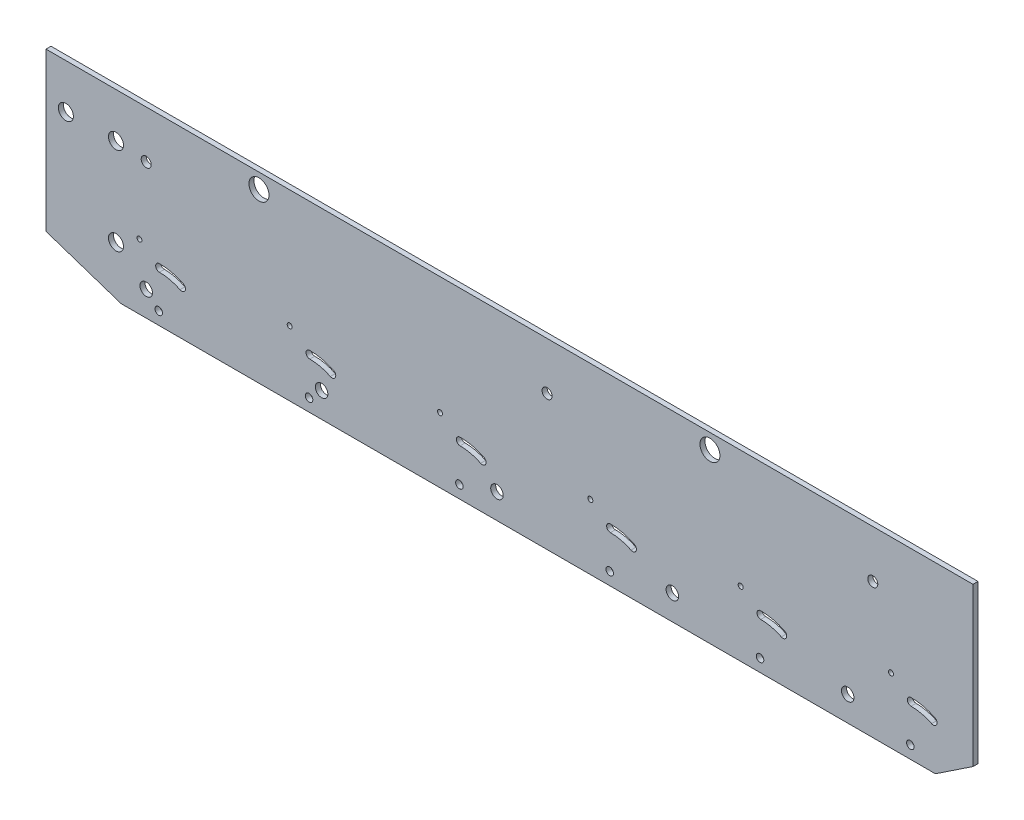
from build123d import *

# Parameters (mm, degrees)
EXTRUDE_1_DEPTH        = 2
SKETCH_2_R             = 1.5
CUT_EXTRUDE_1_DEPTH    = 2
PATTERN_LINEAR_1_COUNT = 6
PATTERN_LINEAR_1_PITCH = 60
SKETCH_3_R             = 2.5
CUT_EXTRUDE_2_DEPTH    = 2
PATTERN_LINEAR_2_COUNT = 5
PATTERN_LINEAR_2_PITCH = 70
SKETCH_4_R             = 2
CUT_EXTRUDE_3_DEPTH    = 2
CUT_EXTRUDE_5_REACH    = 4
SKETCH_6_R             = 3
CUT_EXTRUDE_6_DEPTH    = 2
PATTERN_LINEAR_3_COUNT = 6
PATTERN_LINEAR_3_PITCH = 60
SKETCH_8_R             = 1
CUT_EXTRUDE_7_DEPTH    = 2
PATTERN_LINEAR_4_COUNT = 6
PATTERN_LINEAR_4_PITCH = 60
SKETCH_9_W             = 370
SKETCH_9_H             = 13
EXTRUDE_2_DEPTH        = 2
SKETCH_10_R            = 4
CUT_EXTRUDE_8_DEPTH    = 2


with BuildPart() as part:
    # 草图1 → 凸台-拉伸1 (new body)
    with BuildSketch(Plane.XY):
        Polygon((-162.5, 0), (162.5, 0), (177.5, 10), (177.5, 60), (-192.5, 60), (-192.5, 10), align=None)
    extrude(amount=EXTRUDE_1_DEPTH)

    # 草图2 → 切除-拉伸1 (cut)
    with BuildSketch(Plane.XY.offset(2)):
        with Locations((-147.5, 5)):
            Circle(SKETCH_2_R)
    cut_extrude_1 = extrude(amount=-CUT_EXTRUDE_1_DEPTH, mode=Mode.SUBTRACT)

    # 阵列(线性)1: 切除-拉伸1 ×6
    with Locations(*[(i * PATTERN_LINEAR_1_PITCH, 0, 0) for i in range(1, PATTERN_LINEAR_1_COUNT)]):
        add(cut_extrude_1, mode=Mode.SUBTRACT)

    # 草图3 → 切除-拉伸2 (cut)
    with BuildSketch(Plane.XY.offset(2)):
        with Locations((-152.5, 10)):
            Circle(SKETCH_3_R)
    cut_extrude_2 = extrude(amount=-CUT_EXTRUDE_2_DEPTH, mode=Mode.SUBTRACT)

    # 阵列(线性)2: 切除-拉伸2 ×5
    with Locations(*[(i * PATTERN_LINEAR_2_PITCH, 0, 0) for i in range(1, PATTERN_LINEAR_2_COUNT)]):
        add(cut_extrude_2, mode=Mode.SUBTRACT)

    # 草图4 → 切除-拉伸3 (cut)
    with BuildSketch(Plane.XY.offset(2)):
        with Locations((-152.5, 54)):
            Circle(SKETCH_4_R)
        with Locations((7.5, 54)):
            Circle(SKETCH_4_R)
        with Locations((137.5, 54)):
            Circle(SKETCH_4_R)
    extrude(amount=-CUT_EXTRUDE_3_DEPTH, mode=Mode.SUBTRACT)

    # 草图6 → 切除-拉伸5 (cut, up to next)
    with BuildSketch(Plane.XY.offset(2), mode=Mode.PRIVATE) as cut_extrude_5_sk1:
        with Locations((-184.57, 55.21)):
            Circle(SKETCH_6_R)
    cut_extrude_5_tool1 = extrude(cut_extrude_5_sk1.sketch, amount=-CUT_EXTRUDE_5_REACH, mode=Mode.PRIVATE) & part.part
    add(cut_extrude_5_tool1.solids().sort_by_distance((-184.57, 55.21, 2))[0], mode=Mode.SUBTRACT)
    # 草图6 → 切除-拉伸5 (cut, up to next)
    with BuildSketch(Plane.XY.offset(2), mode=Mode.PRIVATE) as cut_extrude_5_sk2:
        with Locations((-164.57, 55.21)):
            Circle(SKETCH_6_R)
    cut_extrude_5_tool2 = extrude(cut_extrude_5_sk2.sketch, amount=-CUT_EXTRUDE_5_REACH, mode=Mode.PRIVATE) & part.part
    add(cut_extrude_5_tool2.solids().sort_by_distance((-164.57, 55.21, 2))[0], mode=Mode.SUBTRACT)
    # 草图6 → 切除-拉伸5 (cut, up to next)
    with BuildSketch(Plane.XY.offset(2), mode=Mode.PRIVATE) as cut_extrude_5_sk3:
        with Locations((-164.57, 20.21)):
            Circle(SKETCH_6_R)
    cut_extrude_5_tool3 = extrude(cut_extrude_5_sk3.sketch, amount=-CUT_EXTRUDE_5_REACH, mode=Mode.PRIVATE) & part.part
    add(cut_extrude_5_tool3.solids().sort_by_distance((-164.57, 20.21, 2))[0], mode=Mode.SUBTRACT)

    # 草图7 → 切除-拉伸6 (cut)
    with BuildSketch(Plane.XY.offset(2)):
        with BuildLine():
            ThreePointArc((-147.22, 21.5), (-148.72, 20), (-147.22, 18.5))
            ThreePointArc((-147.22, 18.5), (-143.000780895, 18.012446152), (-139.003950762, 16.575481472))
            ThreePointArc((-139.003950762, 16.575481472), (-136.993826903, 17.253273526), (-137.671618958, 19.263397386))
            ThreePointArc((-137.671618958, 19.263397386), (-142.316583462, 20.933383309), (-147.22, 21.5))
        make_face()
    cut_extrude_6 = extrude(amount=-CUT_EXTRUDE_6_DEPTH, mode=Mode.SUBTRACT)

    # 阵列(线性)3: 切除-拉伸6 ×6
    with Locations(*[(i * PATTERN_LINEAR_3_PITCH, 0, 0) for i in range(1, PATTERN_LINEAR_3_COUNT)]):
        add(cut_extrude_6, mode=Mode.SUBTRACT)

    # 草图8 → 切除-拉伸7 (cut)
    with BuildSketch(Plane.XY.offset(2)):
        with Locations((-155.22, 26)):
            Circle(SKETCH_8_R)
    cut_extrude_7 = extrude(amount=-CUT_EXTRUDE_7_DEPTH, mode=Mode.SUBTRACT)

    # 阵列(线性)4: 切除-拉伸7 ×6
    with Locations(*[(i * PATTERN_LINEAR_4_PITCH, 0, 0) for i in range(1, PATTERN_LINEAR_4_COUNT)]):
        add(cut_extrude_7, mode=Mode.SUBTRACT)

    # 草图9 → 凸台-拉伸2 (add)
    with BuildSketch(Plane.XY):
        with Locations((-7.5, 66.5)):
            Rectangle(SKETCH_9_W, SKETCH_9_H)
    extrude(amount=EXTRUDE_2_DEPTH)

    # 草图10 → 切除-拉伸8 (cut)
    with BuildSketch(Plane.XY.offset(2)):
        with Locations((-107.5, 67)):
            Circle(SKETCH_10_R)
        with Locations((72.5, 67)):
            Circle(SKETCH_10_R)
    extrude(amount=-CUT_EXTRUDE_8_DEPTH, mode=Mode.SUBTRACT)


solid = part.part
